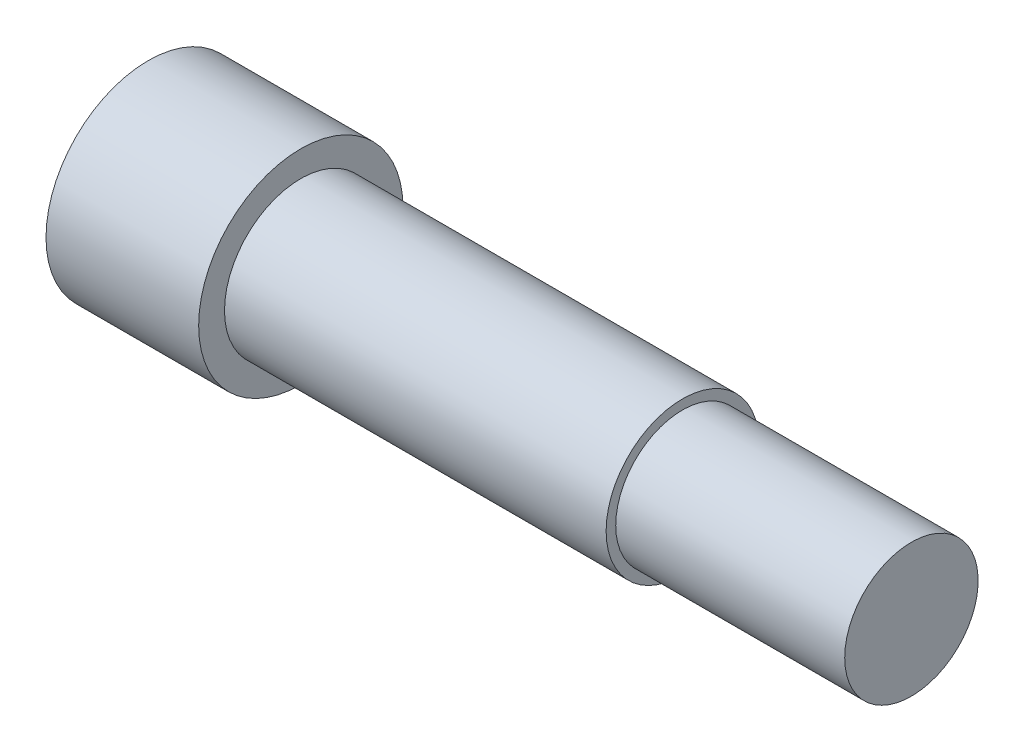
from build123d import *


with BuildPart() as part:
    # Sketch1 → Revolve1 (revolve)
    with BuildSketch(Plane.XY):
        Polygon((0, 0), (63.5, 0), (63.5, 5.5499), (44.45, 5.5499), (44.45, 6.35), (12.7, 6.35), (12.7, 8.500000018), (0, 8.500000018), align=None)
    revolve(axis=Axis((0, 0, 0), (1, 0, 0)))


solid = part.part
